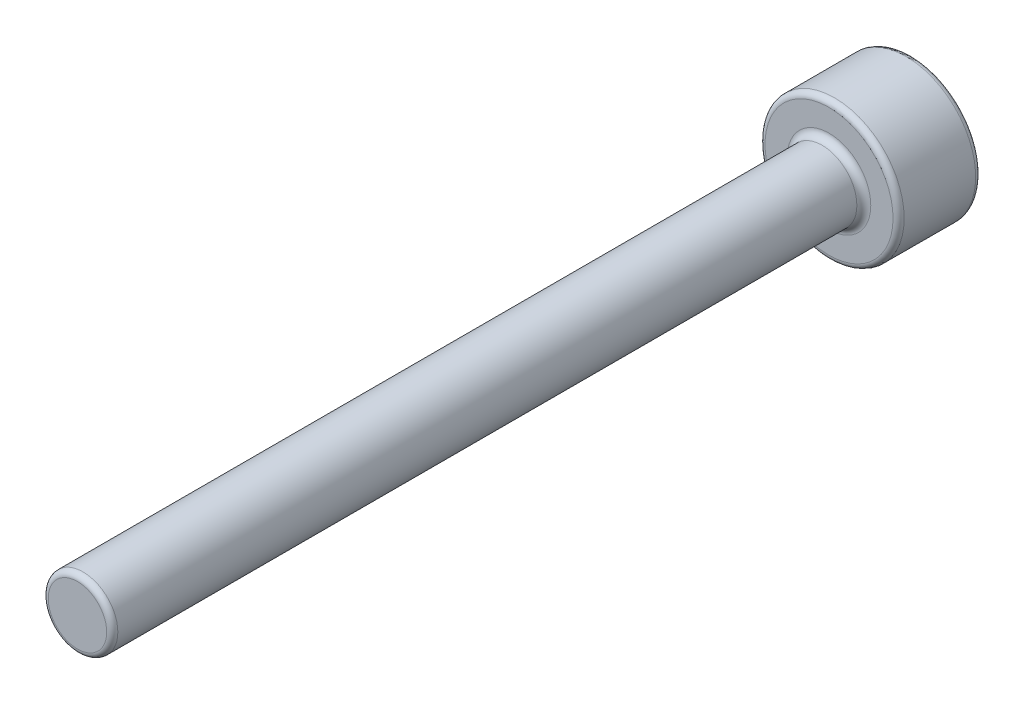
from build123d import *

# Parameters (mm, degrees)
SKETCH_1_R            = 5
EXTRUDE_490_DEPTH     = 6
SKETCH_2_R            = 2.5
EXTRUDE_581_DEPTH     = 54
CUT_EXTRUDE_774_DEPTH = 3
CHAMFER_830_SIZE2     = 0.4
CHAMFER_830_SIZE      = 0.230940108
FILLET_881_R          = 0.5
FILLET_2_R            = 0.4


with BuildPart() as part:
    # 草圖1 → Extrude 490 (new body)
    with BuildSketch(Plane.XY):
        Circle(SKETCH_1_R)
    extrude(amount=EXTRUDE_490_DEPTH)

    # 草圖2 → Extrude 581 (add)
    with BuildSketch(Plane.XY.offset(6)):
        Circle(SKETCH_2_R)
    extrude(amount=EXTRUDE_581_DEPTH)

    # 草圖3 → Cut-Extrude 774 (cut)
    with BuildSketch(Plane(origin=(0, 0, 0), x_dir=(-1, 0, 0), z_dir=(0, 0, -1))):
        Polygon((2.5, -1.443375673), (2.5, 1.443375673), (0, 2.886751346), (-2.5, 1.443375673), (-2.5, -1.443375673), (0, -2.886751346), align=None)
    extrude(amount=-CUT_EXTRUDE_774_DEPTH, mode=Mode.SUBTRACT)

    # Chamfer 830
    chamfer_830_edges = [part.edges().sort_by_distance(p)[0] for p in [
        (-5, 0, 0),
    ]]
    chamfer(chamfer_830_edges, length=CHAMFER_830_SIZE, length2=CHAMFER_830_SIZE2)

    # Fillet 881
    fillet_881_edges = [part.edges().sort_by_distance(p)[0] for p in [
        (-2.5, 0, 6),
    ]]
    fillet(fillet_881_edges, radius=FILLET_881_R)

    # 圓角2
    fillet_2_edges = [part.edges().sort_by_distance(p)[0] for p in [
        (-1.25, -2.165063509, 3),
        (1.25, -2.165063509, 3),
        (2.5, 0, 3),
        (1.25, 2.165063509, 3),
        (-1.25, 2.165063509, 3),
        (-2.5, 0, 3),
        (-1.25, -2.165063509, 0),
        (-2.5, 0, 0),
        (-1.25, 2.165063509, 0),
        (1.25, 2.165063509, 0),
        (2.5, 0, 0),
        (1.25, -2.165063509, 0),
        (-5, 0, 0.230940108),
        (-4.6, 0, 0),
        (-5, 0, 6),
        (-2.5, 0, 60),
    ]]
    fillet(fillet_2_edges, radius=FILLET_2_R)


solid = part.part
